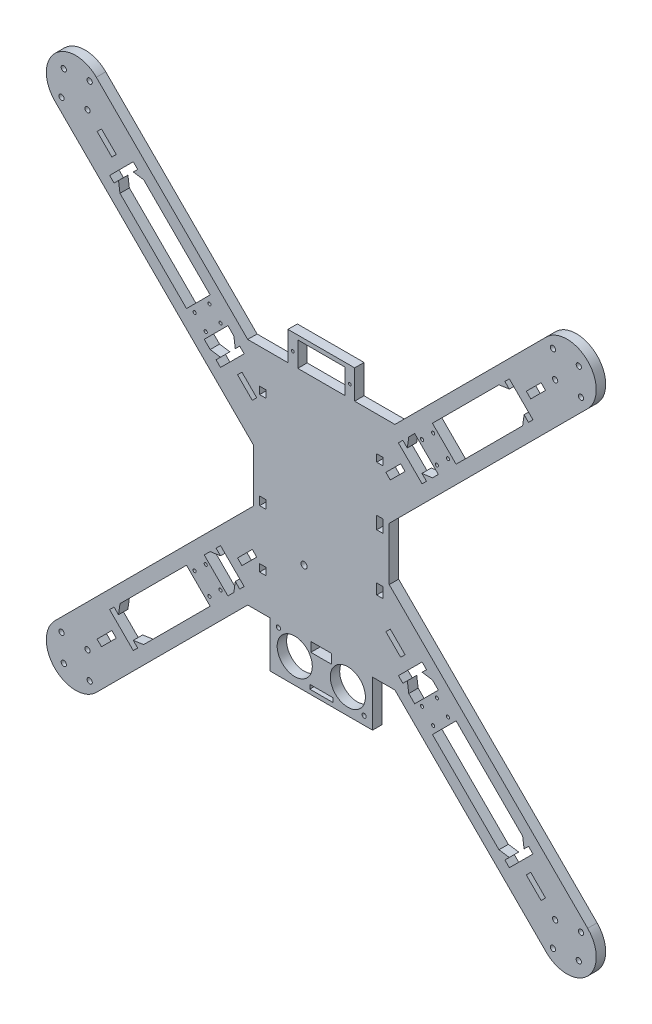
from build123d import *

# Parameters (mm, degrees)
BOSS_EXTRUDE1_DEPTH = 4.5
SKETCH4_R           = 1.25
CUT_EXTRUDE1_DEPTH  = 4.5
SKETCH5_R           = 0.65
SKETCH5_W           = 22.5
SKETCH5_H           = 11.8
CUT_EXTRUDE2_DEPTH  = 4.5
SKETCH6_R           = 1.5
CUT_EXTRUDE3_DEPTH  = 4.5
SKETCH7_R           = 1
SKETCH7_R_2         = 8.4
SKETCH7_W           = 10
SKETCH7_H           = 4.5
SKETCH7_W_2         = 11
SKETCH7_H_2         = 2
CUT_EXTRUDE4_DEPTH  = 4.5
CUT_EXTRUDE5_DEPTH  = 5.5
BOSS_EXTRUDE2_REACH = 195.969
SKETCH9_W           = 4.5
SKETCH9_H           = 12
BOSS_EXTRUDE3_REACH = 195.969
SKETCH11_W          = 4.5
SKETCH11_H          = 12
BOSS_EXTRUDE4_REACH = 195.969
SKETCH12_W          = 4.5
SKETCH12_H          = 12
BOSS_EXTRUDE5_REACH = 195.969
SKETCH13_W          = 4.5
SKETCH13_H          = 12
SKETCH14_W          = 3
SKETCH14_H          = 6
SKETCH14_H_2        = 3.5
SKETCH14_H_3        = 4
SKETCH14_H_4        = 5
CUT_EXTRUDE6_DEPTH  = 5.5
SKETCH15_R          = 0.75
CUT_EXTRUDE7_DEPTH  = 5.5


with BuildPart() as part:
    # Sketch1 → Boss-Extrude1 (new body)
    with BuildSketch(Plane.XY):
        with BuildLine():
            Line((35.201010127, 55), (15.95, 55))
            Line((15.95, 55), (15.95, 68.8))
            Line((15.95, 68.8), (-15.95, 68.8))
            Line((-15.95, 68.8), (-15.95, 55))
            Line((-15.95, 55), (-35.201010127, 55))
            Line((-35.201010127, 55), (-107.600505063, 127.399494937))
            ThreePointArc((-107.600505063, 127.399494937), (-127.399494937, 127.399494937), (-127.399494937, 107.600505063))
            Line((-127.399494937, 107.600505063), (-32.5, 12.701010127))
            Line((-32.5, 12.701010127), (-32.5, -12.701010127))
            Line((-32.5, -12.701010127), (-127.399494937, -107.600505063))
            ThreePointArc((-127.399494937, -107.600505063), (-127.399494937, -127.399494937), (-107.600505063, -127.399494937))
            Line((-107.600505063, -127.399494937), (-35.201010127, -55))
            Line((-35.201010127, -55), (-24.5, -55))
            Line((-24.5, -55), (-24.5, -77))
            Line((-24.5, -77), (24.5, -77))
            Line((24.5, -77), (24.5, -55))
            Line((24.5, -55), (35.201010127, -55))
            Line((35.201010127, -55), (107.600505063, -127.399494937))
            ThreePointArc((107.600505063, -127.399494937), (127.399494937, -127.399494937), (127.399494937, -107.600505063))
            Line((127.399494937, -107.600505063), (32.5, -12.701010127))
            Line((32.5, -12.701010127), (32.5, 12.701010127))
            Line((32.5, 12.701010127), (127.399494937, 107.600505063))
            ThreePointArc((127.399494937, 107.600505063), (127.399494937, 127.399494937), (107.600505063, 127.399494937))
            Line((107.600505063, 127.399494937), (35.201010127, 55))
        make_face()
    extrude(amount=-BOSS_EXTRUDE1_DEPTH)

    # Sketch4 → Cut-Extrude1 (cut)
    with BuildSketch(Plane.XY):
        with Locations((-110.782485579, 124.217514421)):
            Circle(SKETCH4_R)
        with Locations((-124.217514421, 110.782485579)):
            Circle(SKETCH4_R)
        with Locations((-123.156854249, 123.156854249)):
            Circle(SKETCH4_R)
        with Locations((-111.843145751, 111.843145751)):
            Circle(SKETCH4_R)
        with Locations((111.843145751, 111.843145751)):
            Circle(SKETCH4_R)
        with Locations((110.782485579, 124.217514421)):
            Circle(SKETCH4_R)
        with Locations((123.156854249, 123.15685425)):
            Circle(SKETCH4_R)
        with Locations((124.217514421, 110.782485579)):
            Circle(SKETCH4_R)
        with Locations((111.843145751, -111.84314575)):
            Circle(SKETCH4_R)
        with Locations((124.217514421, -110.782485579)):
            Circle(SKETCH4_R)
        with Locations((123.15685425, -123.156854249)):
            Circle(SKETCH4_R)
        with Locations((110.782485579, -124.217514421)):
            Circle(SKETCH4_R)
        with Locations((-111.84314575, -111.843145751)):
            Circle(SKETCH4_R)
        with Locations((-110.782485579, -124.217514421)):
            Circle(SKETCH4_R)
        with Locations((-123.156854249, -123.156854249)):
            Circle(SKETCH4_R)
        with Locations((-124.217514421, -110.782485579)):
            Circle(SKETCH4_R)
    extrude(amount=-CUT_EXTRUDE1_DEPTH, mode=Mode.SUBTRACT)

    # Sketch5 → Cut-Extrude2 (cut)
    with BuildSketch(Plane.XY):
        with Locations((-13.65, 60.9)):
            Circle(SKETCH5_R)
        with Locations((13.65, 60.9)):
            Circle(SKETCH5_R)
        with Locations((0, 60.9)):
            Rectangle(SKETCH5_W, SKETCH5_H)
    extrude(amount=-CUT_EXTRUDE2_DEPTH, mode=Mode.SUBTRACT)

    # Sketch6 → Cut-Extrude3 (cut)
    with BuildSketch(Plane.XY):
        with Locations((-8.25, -25)):
            Circle(SKETCH6_R)
    extrude(amount=-CUT_EXTRUDE3_DEPTH, mode=Mode.SUBTRACT)

    # Sketch7 → Cut-Extrude4 (cut)
    with BuildSketch(Plane.XY):
        with Locations((-20.5, -57)):
            Circle(SKETCH7_R)
        with Locations((-12.7, -65)):
            Circle(SKETCH7_R_2)
        with Locations((12.7, -65)):
            Circle(SKETCH7_R_2)
        with Locations((20.5, -73)):
            Circle(SKETCH7_R)
        with Locations((0, -57.25)):
            Rectangle(SKETCH7_W, SKETCH7_H)
        with Locations((0, -74)):
            Rectangle(SKETCH7_W_2, SKETCH7_H_2)
    extrude(amount=-CUT_EXTRUDE4_DEPTH, mode=Mode.SUBTRACT)

    # Sketch8 → Cut-Extrude5 (cut, through all)
    with BuildSketch(Plane.XY):
        Polygon((101.236544033, -89.922835534), (89.922835534, -101.236544033), (87.80151519, -99.115223689), (89.922835534, -96.993903346), (84.973088065, -96.286796564), (41.839574413, -53.153282912), (41.132467632, -48.203535444), (39.011147288, -50.324855787), (36.889826945, -48.203535444), (48.203535444, -36.889826945), (50.324855787, -39.011147288), (48.203535444, -41.132467632), (53.153282912, -41.839574413), (96.286796564, -84.973088065), (96.993903346, -89.922835534), (99.115223689, -87.80151519), align=None)
        Polygon((40.07180746, -37.950487117), (37.950487117, -40.07180746), (30.879419305, -33.000739648), (33.000739648, -30.879419305), align=None)
        Polygon((50.324855787, 39.011147288), (48.203535444, 36.889826945), (36.889826945, 48.203535444), (39.011147288, 50.324855787), (41.132467632, 48.203535444), (41.839574413, 53.153282912), (84.973088065, 96.286796564), (89.922835534, 96.993903346), (87.80151519, 99.115223689), (89.922835534, 101.236544033), (101.236544033, 89.922835534), (99.115223689, 87.80151519), (96.993903346, 89.922835534), (96.286796564, 84.973088065), (53.153282912, 41.839574413), (48.142875272, 41.193127804), align=None)
        Polygon((100.175883861, -98.054563517), (98.054563517, -100.175883861), (105.125631329, -107.246951673), (107.246951673, -105.125631329), align=None)
        Polygon((-101.236544033, -89.922835534), (-99.115223689, -87.80151519), (-96.993903346, -89.922835534), (-96.286796564, -84.973088065), (-53.153282912, -41.839574413), (-48.203535444, -41.132467632), (-50.324855787, -39.011147288), (-48.203535444, -36.889826945), (-36.889826945, -48.203535444), (-39.011147288, -50.324855787), (-41.132467632, -48.203535444), (-41.839574413, -53.153282912), (-84.973088065, -96.286796564), (-89.922835534, -96.993903346), (-87.80151519, -99.115223689), (-89.922835534, -101.236544033), align=None)
        Polygon((-100.175883861, -98.054563517), (-107.246951673, -105.125631329), (-105.125631329, -107.246951673), (-98.054563517, -100.175883861), align=None)
        Polygon((-37.950487117, -40.07180746), (-40.07180746, -37.950487117), (-33.000739648, -30.879419305), (-30.879419305, -33.000739648), align=None)
        Polygon((-89.922835534, 101.236544033), (-87.80151519, 99.115223689), (-89.922835534, 96.993903346), (-84.973088065, 96.286796564), (-41.839574413, 53.153282912), (-41.132467632, 48.203535444), (-39.011147288, 50.324855787), (-36.889826945, 48.203535444), (-48.203535444, 36.889826945), (-50.324855787, 39.011147288), (-48.203535444, 41.132467632), (-53.153282912, 41.839574413), (-96.286796564, 84.973088065), (-96.993903346, 89.922835534), (-99.115223689, 87.80151519), (-101.236544033, 89.922835534), align=None)
        Polygon((-98.054563517, 100.175883861), (-105.125631329, 107.246951673), (-107.246951673, 105.125631329), (-100.175883861, 98.054563517), align=None)
        Polygon((-40.07180746, 37.950487117), (-37.950487117, 40.07180746), (-30.879419305, 33.000739648), (-33.000739648, 30.879419305), align=None)
        Polygon((100.175883861, 98.054563517), (107.246951673, 105.125631329), (105.125631329, 107.246951673), (98.054563517, 100.175883861), align=None)
        Polygon((37.950487117, 40.07180746), (40.07180746, 37.950487117), (33.000739648, 30.879419305), (30.879419305, 33.000739648), align=None)
    extrude(amount=-CUT_EXTRUDE5_DEPTH, mode=Mode.SUBTRACT)

    # Sketch9 → Boss-Extrude2 (add, up to next)
    with BuildSketch(Plane(origin=(-5.656854249, 5.656854249, 0), x_dir=(0, 0, -1), z_dir=(0.707106781, -0.707106781, 0)), mode=Mode.PRIVATE) as boss_extrude2_sk1:
        with Locations((2.25, 77.170093579)):
            Rectangle(SKETCH9_W, SKETCH9_H)
    boss_extrude2_tool1 = extrude(boss_extrude2_sk1.sketch, amount=BOSS_EXTRUDE2_REACH, mode=Mode.PRIVATE) - part.part
    add(boss_extrude2_tool1.solids().sort_by_distance((48.910642, 60.224351, -2.25))[0])

    # Sketch11 → Boss-Extrude3 (add, up to next)
    with BuildSketch(Plane(origin=(5.656854249, 5.656854249, 0), x_dir=(0, 0, 1), z_dir=(-0.707106781, -0.707106781, 0)), mode=Mode.PRIVATE) as boss_extrude3_sk1:
        with Locations((-2.25, -77.170093579)):
            Rectangle(SKETCH11_W, SKETCH11_H)
    boss_extrude3_tool1 = extrude(boss_extrude3_sk1.sketch, amount=BOSS_EXTRUDE3_REACH, mode=Mode.PRIVATE) - part.part
    add(boss_extrude3_tool1.solids().sort_by_distance((60.224351, -48.910642, -2.25))[0])

    # Sketch12 → Boss-Extrude4 (add, up to next)
    with BuildSketch(Plane(origin=(5.656854249, -5.656854249, 0), x_dir=(0, 0, 1), z_dir=(-0.707106781, 0.707106781, 0)), mode=Mode.PRIVATE) as boss_extrude4_sk1:
        with Locations((-2.25, -77.170093579)):
            Rectangle(SKETCH12_W, SKETCH12_H)
    boss_extrude4_tool1 = extrude(boss_extrude4_sk1.sketch, amount=BOSS_EXTRUDE4_REACH, mode=Mode.PRIVATE) - part.part
    add(boss_extrude4_tool1.solids().sort_by_distance((-48.910642, -60.224351, -2.25))[0])

    # Sketch13 → Boss-Extrude5 (add, up to next)
    with BuildSketch(Plane(origin=(5.656854249, 5.656854249, 0), x_dir=(0, 0, 1), z_dir=(-0.707106781, -0.707106781, 0)), mode=Mode.PRIVATE) as boss_extrude5_sk1:
        with Locations((-2.25, 77.170093579)):
            Rectangle(SKETCH13_W, SKETCH13_H)
    boss_extrude5_tool1 = extrude(boss_extrude5_sk1.sketch, amount=BOSS_EXTRUDE5_REACH, mode=Mode.PRIVATE) - part.part
    add(boss_extrude5_tool1.solids().sort_by_distance((-48.910642, 60.224351, -2.25))[0])

    # Sketch14 → Cut-Extrude6 (cut, through all)
    with BuildSketch(Plane(origin=(0, 0, -4.5), x_dir=(-1, 0, 0), z_dir=(0, 0, -1))):
        with Locations((-28, 10)):
            Rectangle(SKETCH14_W, SKETCH14_H)
        with Locations((28, -36.75)):
            Rectangle(SKETCH14_W, SKETCH14_H_2)
        with Locations((28, -9)):
            Rectangle(SKETCH14_W, SKETCH14_H_3)
        with Locations((28, 36.75)):
            Rectangle(SKETCH14_W, SKETCH14_H_2)
        with Locations((-28, -17.5)):
            Rectangle(SKETCH14_W, SKETCH14_H_4)
        with Locations((-28, 36.75)):
            Rectangle(SKETCH14_W, SKETCH14_H_2)
    extrude(amount=-CUT_EXTRUDE6_DEPTH, mode=Mode.SUBTRACT)

    # Sketch15 → Cut-Extrude7 (cut, through all)
    with BuildSketch(Plane(origin=(0, 0, -4.5), x_dir=(-1, 0, 0), z_dir=(0, 0, -1))):
        with Locations((-60.577904114, -53.506836303)):
            Circle(SKETCH15_R)
        with Locations((-55.274603256, -48.203535444)):
            Circle(SKETCH15_R)
        with Locations((-48.203535444, -55.274603256)):
            Circle(SKETCH15_R)
        with Locations((-53.506836303, -60.577904114)):
            Circle(SKETCH15_R)
        with Locations((-53.506836303, 60.577904114)):
            Circle(SKETCH15_R)
        with Locations((-48.203535444, 55.274603256)):
            Circle(SKETCH15_R)
        with Locations((-60.577904114, 53.506836303)):
            Circle(SKETCH15_R)
        with Locations((-55.274603256, 48.203535444)):
            Circle(SKETCH15_R)
        with Locations((60.577904114, 53.506836303)):
            Circle(SKETCH15_R)
        with Locations((55.274603256, 48.203535444)):
            Circle(SKETCH15_R)
        with Locations((53.506836303, 60.577904114)):
            Circle(SKETCH15_R)
        with Locations((48.203535444, 55.274603256)):
            Circle(SKETCH15_R)
        with Locations((53.506836303, -60.577904114)):
            Circle(SKETCH15_R)
        with Locations((48.203535444, -55.274603256)):
            Circle(SKETCH15_R)
        with Locations((60.577904114, -53.506836303)):
            Circle(SKETCH15_R)
        with Locations((55.274603256, -48.203535444)):
            Circle(SKETCH15_R)
    extrude(amount=-CUT_EXTRUDE7_DEPTH, mode=Mode.SUBTRACT)


solid = part.part
